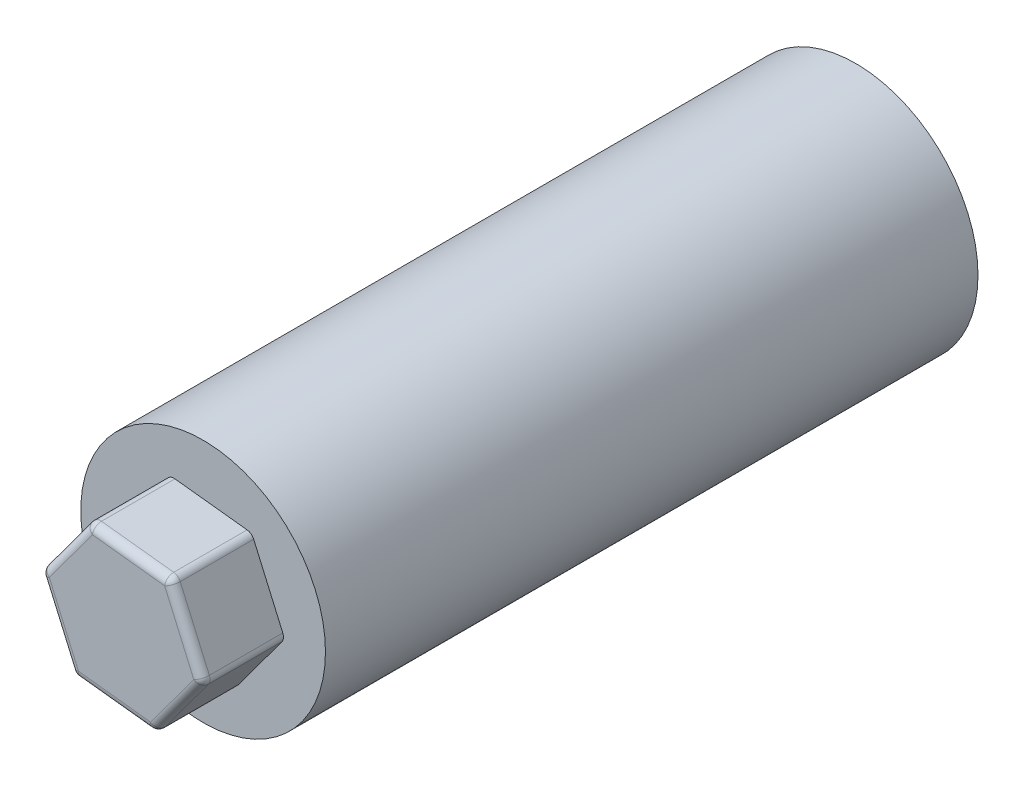
from build123d import *

# Parameters (mm, degrees)
SKETCH1_R           = 15
BOSS_EXTRUDE1_DEPTH = 80
SKETCH2_R           = 4
CUT_EXTRUDE1_DEPTH  = 15
BOSS_EXTRUDE2_DEPTH = 10
FILLET1_R           = 1


with BuildPart() as part:
    # Sketch1 → Boss-Extrude1 (new body)
    with BuildSketch(Plane.XY):
        Circle(SKETCH1_R)
    extrude(amount=BOSS_EXTRUDE1_DEPTH)

    # Sketch2 → Cut-Extrude1 (cut)
    with BuildSketch(Plane(origin=(0, 0, 0), x_dir=(-1, 0, 0), z_dir=(0, 0, -1))):
        Circle(SKETCH2_R)
    extrude(amount=-CUT_EXTRUDE1_DEPTH, mode=Mode.SUBTRACT)

    # Sketch4 → Boss-Extrude2 (add)
    with BuildSketch(Plane.XY.offset(80)):
        Polygon((5.969749807, 8.100368726), (-4.030250193, 9.22013935), (-10, 1.119770624), (-5.969749807, -8.100368726), (4.030250193, -9.22013935), (10, -1.119770624), align=None)
    extrude(amount=BOSS_EXTRUDE2_DEPTH)

    # Fillet1
    fillet1_edges = [part.edges().sort_by_distance(p)[0] for p in [
        (10, -1.119770624, 85),
        (5.969749807, 8.100368726, 85),
        (-4.030250193, 9.22013935, 85),
        (-10, 1.119770624, 85),
        (-5.969749807, -8.100368726, 85),
        (4.030250193, -9.22013935, 85),
        (7.984874903, 3.490299051, 90),
        (0.969749807, 8.660254038, 90),
        (-7.015125097, 5.169954987, 90),
        (-7.984874903, -3.490299051, 90),
        (-0.969749807, -8.660254038, 90),
        (7.015125097, -5.169954987, 90),
    ]]
    fillet(fillet1_edges, radius=FILLET1_R)


solid = part.part
